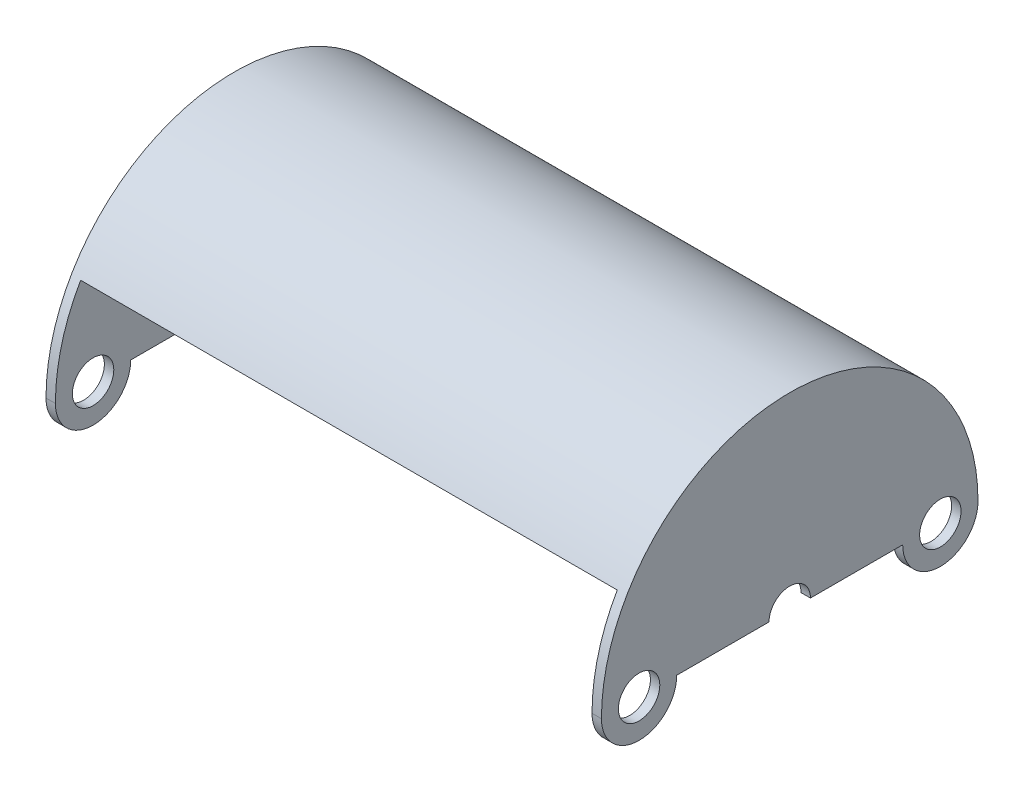
from build123d import *

# Parameters (mm, degrees)
BOSS_EXTRUDE1_DEPTH = 45.24375
SKETCH2_R           = 3.4925
BOSS_EXTRUDE2_DEPTH = 1.5875


with BuildPart() as part:
    # Sketch1 → Boss-Extrude1 (new body, symmetric)
    with BuildSketch(Plane(origin=(0, 0, 0), x_dir=(0, 0, -1), z_dir=(1, 0, 0))):
        with BuildLine():
            ThreePointArc((-26.121491242, 15.08125), (7.806629448, 29.134737735), (30.1625, 0))
            Line((30.1625, 0), (31.75, 0))
            ThreePointArc((31.75, 0), (8.217504682, 30.668144985), (-27.49630657, 15.875))
            Line((-27.49630657, 15.875), (-26.121491242, 15.08125))
        make_face()
    extrude(amount=BOSS_EXTRUDE1_DEPTH, both=True)

    # Sketch2 → Boss-Extrude2 (add)
    with BuildSketch(Plane(origin=(45.24375, 0, 0), x_dir=(0, 0, -1), z_dir=(1, 0, 0))):
        with BuildLine():
            Line((-19.05, 0), (-3.4925, 0))
            ThreePointArc((-3.4925, 0), (0, 3.4925), (3.4925, 0))
            Line((3.4925, 0), (19.05, 0))
            ThreePointArc((19.05, 0), (25.4, -6.35), (31.75, 0))
            ThreePointArc((31.75, 0), (0, 31.75), (-31.75, 0))
            ThreePointArc((-31.75, 0), (-25.4, -6.35), (-19.05, 0))
        make_face()
        with Locations((-25.4, 0)):
            Circle(SKETCH2_R, mode=Mode.SUBTRACT)
        with Locations((25.4, 0)):
            Circle(SKETCH2_R, mode=Mode.SUBTRACT)
    boss_extrude2 = extrude(amount=BOSS_EXTRUDE2_DEPTH)

    # Mirror1: Boss-Extrude2 across plane
    add(boss_extrude2.mirror(Plane(origin=(0, 0, 0), x_dir=(0, 0, 1), z_dir=(1, 0, 0))))


solid = part.part
